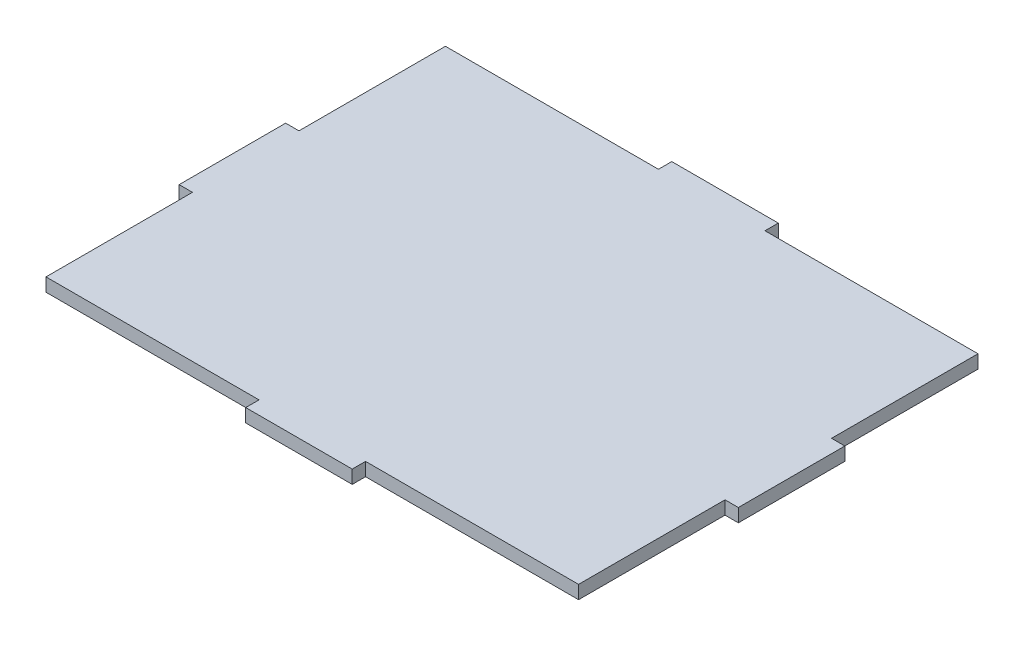
from build123d import *

# Parameters (mm, degrees)
SKETCH1_W           = 127
SKETCH1_H           = 95.25
BOSS_EXTRUDE1_DEPTH = 3.175
SKETCH2_W           = 25.4
SKETCH2_H           = 3.175
BOSS_EXTRUDE2_DEPTH = 3.175
SKETCH3_W           = 25.4
SKETCH3_H           = 3.175
BOSS_EXTRUDE3_DEPTH = 3.175
SKETCH4_W           = 25.4
SKETCH4_H           = 3.175
BOSS_EXTRUDE4_DEPTH = 3.175
SKETCH5_W           = 25.4
SKETCH5_H           = 3.175
BOSS_EXTRUDE5_DEPTH = 3.175


with BuildPart() as part:
    # Sketch1 → Boss-Extrude1 (new body)
    with BuildSketch(Plane(origin=(0, 0, 0), x_dir=(1, 0, 0), z_dir=(0, 1, 0))):
        with Locations((64.375862069, 2.737068966)):
            Rectangle(SKETCH1_W, SKETCH1_H)
    extrude(amount=BOSS_EXTRUDE1_DEPTH)

    # Sketch2 → Boss-Extrude2 (add)
    with BuildSketch(Plane(origin=(127.875862069, 0, 0), x_dir=(0, 0, -1), z_dir=(1, 0, 0))):
        with Locations((2.737068966, 1.5875)):
            Rectangle(SKETCH2_W, SKETCH2_H)
    extrude(amount=BOSS_EXTRUDE2_DEPTH)

    # Sketch3 → Boss-Extrude3 (add)
    with BuildSketch(Plane.ZY.offset(-0.875862069)):
        with Locations((-2.737068966, 1.5875)):
            Rectangle(SKETCH3_W, SKETCH3_H)
    extrude(amount=BOSS_EXTRUDE3_DEPTH)

    # Sketch4 → Boss-Extrude4 (add)
    with BuildSketch(Plane(origin=(0, 0, -50.362068966), x_dir=(-1, 0, 0), z_dir=(0, 0, -1))):
        with Locations((-64.375862069, 1.5875)):
            Rectangle(SKETCH4_W, SKETCH4_H)
    extrude(amount=BOSS_EXTRUDE4_DEPTH)

    # Sketch5 → Boss-Extrude5 (add)
    with BuildSketch(Plane.XY.offset(44.887931034)):
        with Locations((64.375862069, 1.5875)):
            Rectangle(SKETCH5_W, SKETCH5_H)
    extrude(amount=BOSS_EXTRUDE5_DEPTH)


solid = part.part
